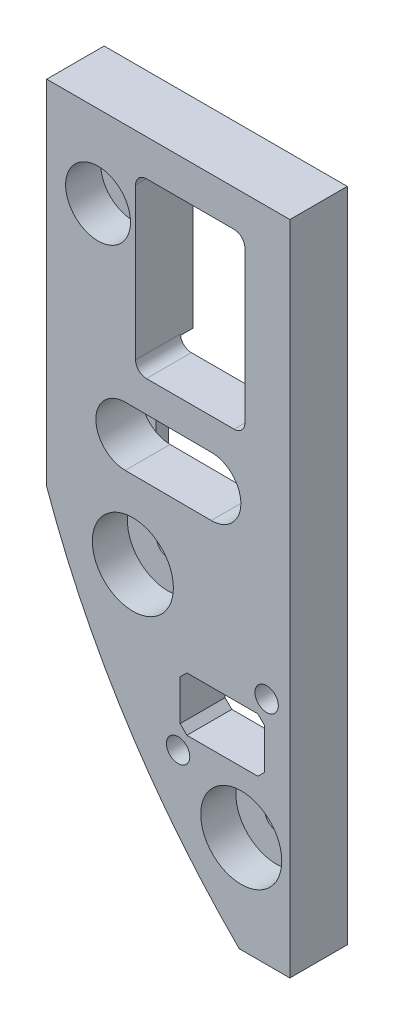
from build123d import *

# Parameters (mm, degrees)
SKETCH1_R           = 2.15265
BOSS_EXTRUDE1_DEPTH = 2.3495
SKETCH2_R           = 2.15265
SKETCH2_R_2         = 2.195581339
SKETCH2_W           = 15.875
SKETCH2_H           = 10.16
BOSS_EXTRUDE2_DEPTH = 8.4455
SKETCH3_R           = 1.22555
BOSS_EXTRUDE3_DEPTH = 2.159
CHAMFER1_SIZE       = 0.254
CHAMFER2_SIZE       = 1.27
SKETCH5_R           = 7.62
SKETCH5_R_2         = 6.096
CUT_EXTRUDE1_DEPTH  = 6.604


with BuildPart() as part:
    # Sketch1 → Boss-Extrude1 (new body)
    with BuildSketch(Plane.XY):
        with BuildLine():
            Line((0, -17.78), (-45.72, -17.78))
            Line((-45.72, -17.78), (-45.72, -84.1375))
            ThreePointArc((-45.72, -84.1375), (-30.833523511, -114.746148224), (-9.525, -141.2875))
            Line((-9.525, -141.2875), (0, -141.2875))
            Line((0, -141.2875), (0, -17.78))
        make_face()
        with Locations((-36.1315, -33.274)):
            Circle(SKETCH1_R, mode=Mode.SUBTRACT)
        with Locations((-29.5275, -88.7095)):
            Circle(SKETCH1_R, mode=Mode.SUBTRACT)
        with BuildLine():
            Line((-1.89756812, -121.923613785), (-1.89756812, -95.571113785))
            Line((-1.89756812, -95.571113785), (-12.166516896, -95.571113785))
            Line((-12.166516896, -95.571113785), (-16.929016896, -90.808613785))
            Line((-16.929016896, -90.808613785), (-23.48756812, -90.808613785))
            Line((-23.48756812, -90.808613785), (-23.48756812, -117.161113785))
            Line((-23.48756812, -117.161113785), (-13.218619344, -117.161113785))
            Line((-13.218619344, -117.161113785), (-9.502774703, -120.876958426))
            ThreePointArc((-9.502774703, -120.876958426), (-10.060883947, -124.947120561), (-7.279497151, -121.923613785))
            Line((-7.279497151, -121.923613785), (-1.89756812, -121.923613785))
        make_face(mode=Mode.SUBTRACT)
        with BuildLine():
            Line((-33.655, -81.7245), (-8.255, -81.7245))
            Line((-8.255, -81.7245), (-8.255, -76.118448776))
            Line((-8.255, -76.118448776), (-12.065, -72.308448776))
            Line((-12.065, -72.308448776), (-12.065, -57.1627))
            Line((-12.065, -57.1627), (-10.4902, -57.1627))
            ThreePointArc((-10.4902, -57.1627), (-9.053359021, -56.567540979), (-8.4582, -55.1307))
            Line((-8.4582, -55.1307), (-8.4582, -26.6573))
            ThreePointArc((-8.4582, -26.6573), (-9.053359021, -25.220459021), (-10.4902, -24.6253))
            Line((-10.4902, -24.6253), (-26.9748, -24.6253))
            ThreePointArc((-26.9748, -24.6253), (-28.411640979, -25.220459021), (-29.0068, -26.6573))
            Line((-29.0068, -26.6573), (-29.0068, -55.372))
            Line((-29.0068, -55.372), (-37.465, -55.372))
            Line((-37.465, -55.372), (-37.465, -60.978051224))
            Line((-37.465, -60.978051224), (-33.655, -64.788051224))
            Line((-33.655, -64.788051224), (-33.655, -81.7245))
        make_face(mode=Mode.SUBTRACT)
    extrude(amount=BOSS_EXTRUDE1_DEPTH)

    # Sketch2 → Boss-Extrude2 (add)
    with BuildSketch(Plane.XY.offset(2.3495)):
        with BuildLine():
            Line((-9.525, -141.2875), (0, -141.2875))
            Line((0, -141.2875), (0, -17.78))
            Line((0, -17.78), (-45.72, -17.78))
            Line((-45.72, -17.78), (-45.72, -84.1375))
            ThreePointArc((-45.72, -84.1375), (-30.833523511, -114.746148224), (-9.525, -141.2875))
        make_face()
        with Locations((-9.144, -122.9995)):
            Circle(SKETCH2_R, mode=Mode.SUBTRACT)
        with Locations((-29.5275, -88.7095)):
            Circle(SKETCH2_R, mode=Mode.SUBTRACT)
        with Locations((-21.016048243, -114.689593907)):
            Circle(SKETCH2_R_2, mode=Mode.SUBTRACT)
        with Locations((-4.369087998, -98.042633662)):
            Circle(SKETCH2_R_2, mode=Mode.SUBTRACT)
        with Locations((-36.1315, -33.274)):
            Circle(SKETCH2_R, mode=Mode.SUBTRACT)
        with Locations((-12.69256812, -106.366113785)):
            Rectangle(SKETCH2_W, SKETCH2_H, mode=Mode.SUBTRACT)
        with BuildLine():
            Line((-14.798016067, -74.184431866), (-30.952016067, -74.104431866))
            ThreePointArc((-30.952016067, -74.104431866), (-36.480681866, -68.520733933), (-30.896983933, -62.992068134))
            Line((-30.896983933, -62.992068134), (-14.742983933, -63.072068134))
            ThreePointArc((-14.742983933, -63.072068134), (-9.214318134, -68.655766067), (-14.798016067, -74.184431866))
        make_face(mode=Mode.SUBTRACT)
        with BuildLine():
            Line((-8.4582, -55.1307), (-8.4582, -26.6573))
            ThreePointArc((-8.4582, -26.6573), (-9.053359021, -25.220459021), (-10.4902, -24.6253))
            Line((-10.4902, -24.6253), (-26.9748, -24.6253))
            ThreePointArc((-26.9748, -24.6253), (-28.411640979, -25.220459021), (-29.0068, -26.6573))
            Line((-29.0068, -26.6573), (-29.0068, -55.1307))
            ThreePointArc((-29.0068, -55.1307), (-28.411640979, -56.567540979), (-26.9748, -57.1627))
            Line((-26.9748, -57.1627), (-10.4902, -57.1627))
            ThreePointArc((-10.4902, -57.1627), (-9.053359021, -56.567540979), (-8.4582, -55.1307))
        make_face(mode=Mode.SUBTRACT)
    extrude(amount=BOSS_EXTRUDE2_DEPTH)

    # Sketch3 → Boss-Extrude3 (add)
    with BuildSketch(Plane(origin=(0, 0, 2.3495), x_dir=(-1, 0, 0), z_dir=(0, 0, -1))):
        with Locations((34.29, -58.547)):
            Circle(SKETCH3_R)
        with Locations((11.43, -78.5495)):
            Circle(SKETCH3_R)
        with Locations((5.54881812, -118.272363785)):
            Circle(SKETCH3_R)
        with Locations((19.83631812, -94.459863785)):
            Circle(SKETCH3_R)
    extrude(amount=BOSS_EXTRUDE3_DEPTH)

    # Chamfer1
    chamfer1_edges = [part.edges().sort_by_distance(p)[0] for p in [
        (-33.06445, -58.547, 0.1905),
        (-10.20445, -78.5495, 0.1905),
        (-4.32326812, -118.272363785, 0.1905),
        (-18.61076812, -94.459863785, 0.1905),
    ]]
    chamfer(chamfer1_edges, length=CHAMFER1_SIZE)

    # Chamfer2
    chamfer2_edges = [part.edges().sort_by_distance(p)[0] for p in [
        (-20.63006812, -111.446113785, 6.57225),
        (-4.75506812, -111.446113785, 6.57225),
        (-4.75506812, -101.286113785, 6.57225),
        (-20.63006812, -101.286113785, 6.57225),
    ]]
    chamfer(chamfer2_edges, length=CHAMFER2_SIZE)

    # Sketch5 → Cut-Extrude1 (cut)
    with BuildSketch(Plane.XY.offset(10.795)):
        with Locations((-9.144, -122.9995)):
            Circle(SKETCH5_R)
        with Locations((-29.5275, -88.7095)):
            Circle(SKETCH5_R)
        with Locations((-36.068, -33.2105)):
            Circle(SKETCH5_R_2)
    extrude(amount=-CUT_EXTRUDE1_DEPTH, mode=Mode.SUBTRACT)


solid = part.part
